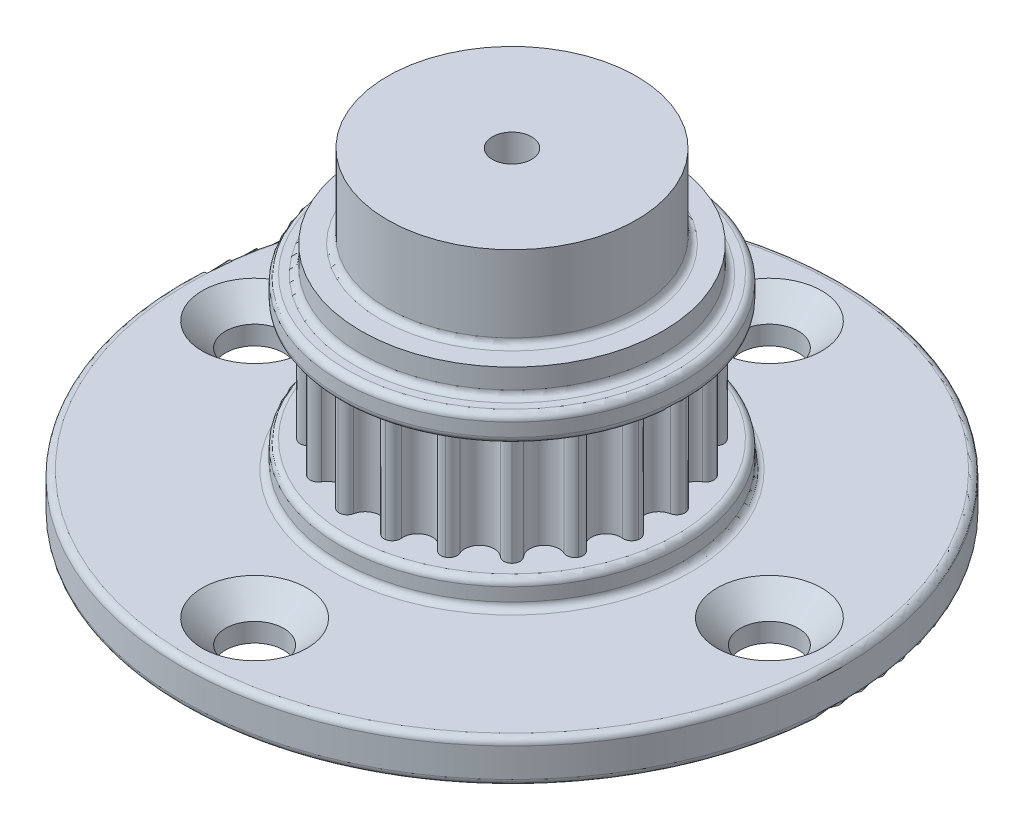
from build123d import *

# Parameters (mm, degrees)
BOSS_EXTRUDE1_DEPTH     = 3.556
CIRPATTERN1_COUNT       = 20
SKETCH2_W               = 10.342329408
SKETCH2_H               = 1.5875
SKETCH9_R               = 19.84375
SKETCH9_R_2             = 1.5
BOSS_EXTRUDE2_DEPTH     = 2.54
SKETCH3_R               = 1.74625
CUT_EXTRUDE1_DEPTH      = 6.087499985
CUT_EXTRUDE1_DEPTH_BACK = 8.627499985
CIRPATTERN2_COUNT       = 4
SKETCH11_R              = 1.5
CUT_EXTRUDE2_DEPTH      = 6
FILLET1_R               = 0.396875


with BuildPart() as part:
    # Sketch1 → Boss-Extrude1 (new body, symmetric)
    with BuildSketch(Plane(origin=(0, 0, 0), x_dir=(1, 0, 0), z_dir=(0, 1, 0))):
        with BuildLine():
            ThreePointArc((0.872060607, 8.659786465), (0.562967303, 8.148255135), (0, 7.947579308))
            ThreePointArc((0, 7.947579308), (-1.243275317, -7.849731418), (2.45593707, 7.55859709))
            ThreePointArc((2.45593707, 7.55859709), (1.982535589, 7.923417607), (1.846642263, 8.505427895))
            ThreePointArc((1.846642263, 8.505427895), (1.749626992, 8.862101959), (1.434119122, 9.054671776))
            ThreePointArc((1.434119122, 9.054671776), (1.074545959, 8.969024291), (0.872060607, 8.659786465))
        make_face()
    boss_extrude1 = extrude(amount=BOSS_EXTRUDE1_DEPTH, both=True)

    # CirPattern1: Boss-Extrude1 ×20 about axis
    cirpattern1_axis = Axis((0, 0, 0), (0, 1, 0))
    for i in range(1, CIRPATTERN1_COUNT):
        add(boss_extrude1.rotate(cirpattern1_axis, i * 360 / CIRPATTERN1_COUNT))

    # Sketch2 → Revolve3 (revolve)
    with BuildSketch(Plane(origin=(0, 0, 0), x_dir=(0, 0, -1), z_dir=(1, 0, 0))):
        with Locations((5.171164704, 4.293749985)):
            Rectangle(SKETCH2_W, SKETCH2_H)
    revolve3 = revolve(axis=Axis((0, 3.3, 0), (0, -1, 0)))

    # Mirror1: Revolve3 across plane
    add(revolve3.mirror(Plane.ZX))

    # Sketch9 → Boss-Extrude2 (add)
    with BuildSketch(Plane.XZ.offset(5.087499985)):
        Circle(SKETCH9_R)
        Circle(SKETCH9_R_2, mode=Mode.SUBTRACT)
    extrude(amount=BOSS_EXTRUDE2_DEPTH)

    # Sketch3 → Cut-Extrude1 (cut, two sides)
    with BuildSketch(Plane(origin=(0, 0, 0), x_dir=(1, 0, 0), z_dir=(0, 1, 0))) as cut_extrude1_sk:
        with Locations((-15.5, 0)):
            Circle(SKETCH3_R)
        with Locations((0, 15.5)):
            Circle(SKETCH3_R)
        with Locations((15.5, 0)):
            Circle(SKETCH3_R)
        with Locations((0, -15.5)):
            Circle(SKETCH3_R)
    extrude(amount=CUT_EXTRUDE1_DEPTH, mode=Mode.SUBTRACT)
    extrude(cut_extrude1_sk.sketch, amount=-CUT_EXTRUDE1_DEPTH_BACK, mode=Mode.SUBTRACT)

    # Sketch6 → Cut-Revolve2 (revolve, cut)
    with BuildSketch(Plane.XY):
        Polygon((-11.8678, -3.499999985), (-15.5, -7.132199985), (-15.5, -3.499999985), align=None)
    cut_revolve2 = revolve(axis=Axis((-15.5, -7.627499985, 0), (0, 1, 0)), mode=Mode.SUBTRACT)

    # Sketch13 → CSK for M3 Flat Head Machine Screw1 (revolve, cut)
    with BuildSketch(Plane(origin=(-15.5, -5.087499985, 0), x_dir=(0, 0, 1), z_dir=(1, 0, 0))):
        Polygon((0, 0), (0, 25.913463052), (1.7, 24.892), (1.7, 1.45), (3.15, 0), align=None)
    csk_for_m3_flat_head_machine_screw1 = revolve(axis=Axis((-15.5, 1.262500015, 0), (0, -1, 0)), mode=Mode.SUBTRACT)

    # CirPattern2: Cut-Revolve2, CSK for M3 Flat Head Machine Screw1 ×4 about axis
    cirpattern2_axis = Axis((0, 0, 0), (0, 1, 0))
    for i in range(1, CIRPATTERN2_COUNT):
        add(cut_revolve2.rotate(cirpattern2_axis, i * 360 / CIRPATTERN2_COUNT), mode=Mode.SUBTRACT)
        add(csk_for_m3_flat_head_machine_screw1.rotate(cirpattern2_axis, i * 360 / CIRPATTERN2_COUNT), mode=Mode.SUBTRACT)

    # Sketch11 → Cut-Extrude2 (cut)
    with BuildSketch(Plane.XZ.offset(5.087499985)):
        Circle(SKETCH11_R)
    extrude(amount=-CUT_EXTRUDE2_DEPTH, mode=Mode.SUBTRACT)

    # Sketch10 → Revolve4 (revolve)
    with BuildSketch(Plane(origin=(0, 0, 0), x_dir=(0, 0, -1), z_dir=(1, 0, 0))):
        Polygon((1.182175065, 6.674999985), (1.182175065, 11.674999985), (7.5, 11.674999985), (7.5, 6.674999985), (9.0875, 6.674999985), (9.0875, 5.087499985), (1.182175065, 5.087499985), align=None)
    revolve(axis=Axis((0, 0, 0), (0, 1, 0)))

    # Fillet1
    fillet1_edges = [part.edges().sort_by_distance(p)[0] for p in [
        (0, 5.087499985, 10.342329408),
        (0, 3.499999985, 10.342329408),
        (0, -3.499999985, 10.342329408),
        (0, -5.087499985, 10.342329408),
        (-19.84375, -7.627499985, 0),
        (-19.84375, -5.087499985, 0),
        (0, 5.087499985, 9.0875),
        (0, 6.674999985, 7.5),
    ]]
    fillet(fillet1_edges, radius=FILLET1_R)


solid = part.part
